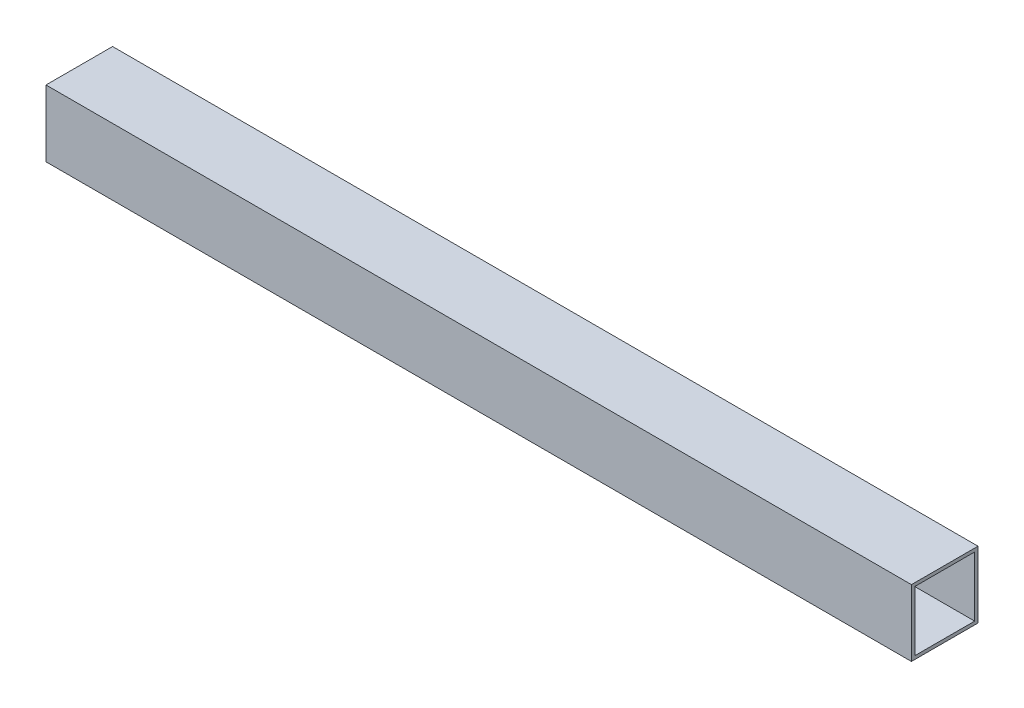
from build123d import *

# Parameters (mm, degrees)
CROQUIS1_W              = 40
CROQUIS1_H              = 40
CROQUIS1_W_2            = 36
CROQUIS1_H_2            = 36
SALIENTE_EXTRUIR1_DEPTH = 520


with BuildPart() as part:
    # Croquis1 → Saliente-Extruir1 (new body)
    with BuildSketch(Plane(origin=(0, 0, 0), x_dir=(0, 0, -1), z_dir=(1, 0, 0))):
        Rectangle(CROQUIS1_W, CROQUIS1_H)
        Rectangle(CROQUIS1_W_2, CROQUIS1_H_2, mode=Mode.SUBTRACT)
    extrude(amount=SALIENTE_EXTRUIR1_DEPTH)


solid = part.part
